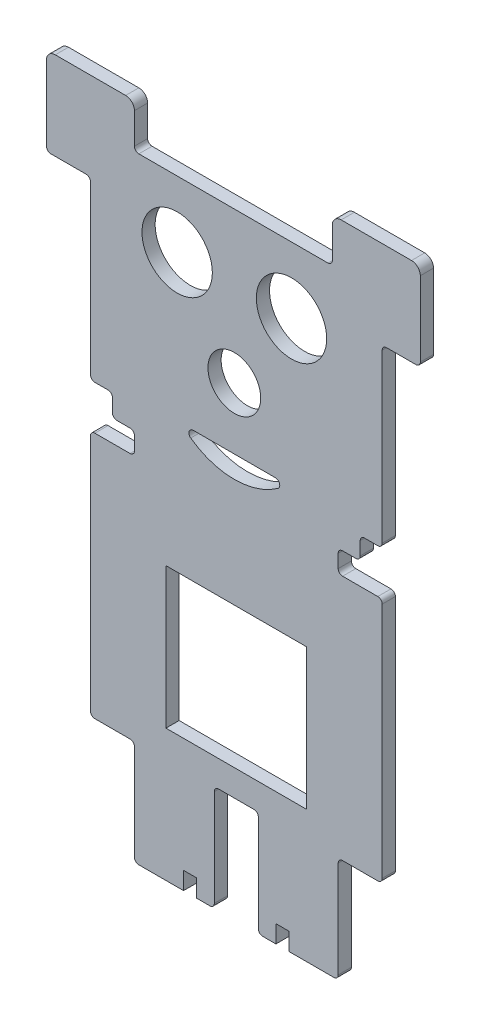
from build123d import *

# Parameters (mm, degrees)
MODEL_R                 = 6
MODEL_R_2               = 8
SALIENTE_EXTRUIR1_DEPTH = 3


with BuildPart() as part:
    # Model → Saliente-Extruir1 (new body)
    with BuildSketch(Plane.XY):
        with BuildLine():
            Line((52.149227215, 40.252), (52.149227215, 37.252))
            ThreePointArc((52.149227215, 37.252), (52.442120434, 36.544893219), (53.149227215, 36.252))
            Line((53.149227215, 36.252), (61.149227215, 36.252))
            ThreePointArc((61.149227215, 36.252), (61.856333997, 35.959106781), (62.149227215, 35.252))
            Line((62.149227215, 35.252), (62.149227215, 12.636622367))
            Line((62.149227215, 12.636622367), (62.149227215, -18.748))
            ThreePointArc((62.149227215, -18.748), (61.856333997, -19.455106781), (61.149227215, -19.748))
            Line((61.149227215, -19.748), (53.149227215, -19.748))
            ThreePointArc((53.149227215, -19.748), (52.442120434, -20.040893219), (52.149227215, -20.748))
            Line((52.149227215, -20.748), (52.149227215, -42.748))
            ThreePointArc((52.149227215, -42.748), (51.856333997, -43.455106781), (51.149227215, -43.748))
            Line((51.149227215, -43.748), (40.985615848, -43.748))
            Line((40.985615848, -43.748), (40.985615848, -39.748))
            Line((40.985615848, -39.748), (37.985615848, -39.748))
            Line((37.985615848, -39.748), (37.985615848, -43.748))
            Line((37.985615848, -43.748), (34.985615848, -43.748))
            ThreePointArc((34.985615848, -43.748), (34.278509066, -43.455106781), (33.985615848, -42.748))
            Line((33.985615848, -42.748), (33.985615848, -20.748))
            ThreePointArc((33.985615848, -20.748), (33.692722629, -20.040893219), (32.985615848, -19.748))
            Line((32.985615848, -19.748), (24.985615848, -19.748))
            ThreePointArc((24.985615848, -19.748), (24.278509066, -20.040893219), (23.985615848, -20.748))
            Line((23.985615848, -20.748), (23.985615848, -42.748))
            ThreePointArc((23.985615848, -42.748), (23.692722629, -43.455106781), (22.985615848, -43.748))
            Line((22.985615848, -43.748), (19.985615848, -43.748))
            Line((19.985615848, -43.748), (19.985615848, -39.748))
            Line((19.985615848, -39.748), (16.985615848, -39.748))
            Line((16.985615848, -39.748), (16.985615848, -43.748))
            Line((16.985615848, -43.748), (6.82200448, -43.748))
            ThreePointArc((6.82200448, -43.748), (6.114897699, -43.455106781), (5.82200448, -42.748))
            Line((5.82200448, -42.748), (5.82200448, -20.969725915))
            ThreePointArc((5.82200448, -20.969725915), (5.529111261, -20.262619134), (4.82200448, -19.969725915))
            Line((4.82200448, -19.969725915), (-3.17799552, -19.969725915))
            ThreePointArc((-3.17799552, -19.969725915), (-3.885102301, -19.676832696), (-4.17799552, -18.969725915))
            Line((-4.17799552, -18.969725915), (-4.17799552, 14.641137042))
            Line((-4.17799552, 14.641137042), (-4.17799552, 35.252))
            ThreePointArc((-4.17799552, 35.252), (-3.885102301, 35.959106781), (-3.17799552, 36.252))
            Line((-3.17799552, 36.252), (4.82200448, 36.252))
            ThreePointArc((4.82200448, 36.252), (5.529111261, 36.544893219), (5.82200448, 37.252))
            Line((5.82200448, 37.252), (5.82200448, 40.252))
            ThreePointArc((5.82200448, 40.252), (5.529111261, 40.959106781), (4.82200448, 41.252))
            Line((4.82200448, 41.252), (1.82200448, 41.252))
            ThreePointArc((1.82200448, 41.252), (1.114897699, 41.544893219), (0.82200448, 42.252))
            Line((0.82200448, 42.252), (0.82200448, 45.252))
            ThreePointArc((0.82200448, 45.252), (0.529111261, 45.959106781), (-0.17799552, 46.252))
            Line((-0.17799552, 46.252), (-3.17799552, 46.252))
            ThreePointArc((-3.17799552, 46.252), (-3.885102301, 46.544893219), (-4.17799552, 47.252))
            Line((-4.17799552, 47.252), (-4.17799552, 85.252))
            ThreePointArc((-4.17799552, 85.252), (-4.470888739, 85.959106781), (-5.17799552, 86.252))
            Line((-5.17799552, 86.252), (-8.67799552, 86.252))
            Line((-8.67799552, 86.252), (-13.17799552, 86.252))
            ThreePointArc((-13.17799552, 86.252), (-13.885102301, 86.544893219), (-14.17799552, 87.252))
            Line((-14.17799552, 87.252), (-14.17799552, 104.252))
            ThreePointArc((-14.17799552, 104.252), (-13.592209082, 105.666213562), (-12.17799552, 106.252))
            Line((-12.17799552, 106.252), (3.82200448, 106.252))
            ThreePointArc((3.82200448, 106.252), (5.236218042, 105.666213562), (5.82200448, 104.252))
            Line((5.82200448, 104.252), (5.82200448, 97.252))
            ThreePointArc((5.82200448, 97.252), (6.114897699, 96.544893219), (6.82200448, 96.252))
            Line((6.82200448, 96.252), (49.82200448, 96.252))
            ThreePointArc((49.82200448, 96.252), (50.529111261, 96.544893219), (50.82200448, 97.252))
            Line((50.82200448, 97.252), (50.82200448, 104.252))
            ThreePointArc((50.82200448, 104.252), (51.407790918, 105.666213562), (52.82200448, 106.252))
            Line((52.82200448, 106.252), (68.82200448, 106.252))
            ThreePointArc((68.82200448, 106.252), (70.236218042, 105.666213562), (70.82200448, 104.252))
            Line((70.82200448, 104.252), (70.82200448, 87.252))
            ThreePointArc((70.82200448, 87.252), (70.529111261, 86.544893219), (69.82200448, 86.252))
            Line((69.82200448, 86.252), (63.149227215, 86.252))
            ThreePointArc((63.149227215, 86.252), (62.442120434, 85.959106781), (62.149227215, 85.252))
            Line((62.149227215, 85.252), (62.149227215, 66.752))
            Line((62.149227215, 66.752), (62.149227215, 47.252))
            ThreePointArc((62.149227215, 47.252), (61.856333997, 46.544893219), (61.149227215, 46.252))
            Line((61.149227215, 46.252), (58.149227215, 46.252))
            ThreePointArc((58.149227215, 46.252), (57.442120434, 45.959106781), (57.149227215, 45.252))
            Line((57.149227215, 45.252), (57.149227215, 42.252))
            ThreePointArc((57.149227215, 42.252), (56.856333997, 41.544893219), (56.149227215, 41.252))
            Line((56.149227215, 41.252), (53.149227215, 41.252))
            ThreePointArc((53.149227215, 41.252), (52.442120434, 40.959106781), (52.149227215, 40.252))
        make_face()
        with Locations((28.532877275, 62.00057999)):
            Circle(MODEL_R, mode=Mode.SUBTRACT)
        with Locations((41.532877275, 81.20057999)):
            Circle(MODEL_R_2, mode=Mode.SUBTRACT)
        with Locations((15.532877275, 81.20057999)):
            Circle(MODEL_R_2, mode=Mode.SUBTRACT)
        Polygon((12.985615848, 18.252), (29.485615848, 18.252), (44.985615848, 18.252), (44.985615848, -13.748), (12.985615848, -13.748), align=None, mode=Mode.SUBTRACT)
        with BuildLine():
            Line((37.863153208, 48.00057999), (19.202601343, 48.00057999))
            ThreePointArc((19.202601343, 48.00057999), (18.250601998, 47.306680051), (18.619787227, 46.187974485))
            ThreePointArc((18.619787227, 46.187974485), (28.532877275, 43.00057999), (38.445967323, 46.187974485))
            ThreePointArc((38.445967323, 46.187974485), (38.815152552, 47.306680051), (37.863153208, 48.00057999))
        make_face(mode=Mode.SUBTRACT)
    extrude(amount=SALIENTE_EXTRUIR1_DEPTH)


solid = part.part
